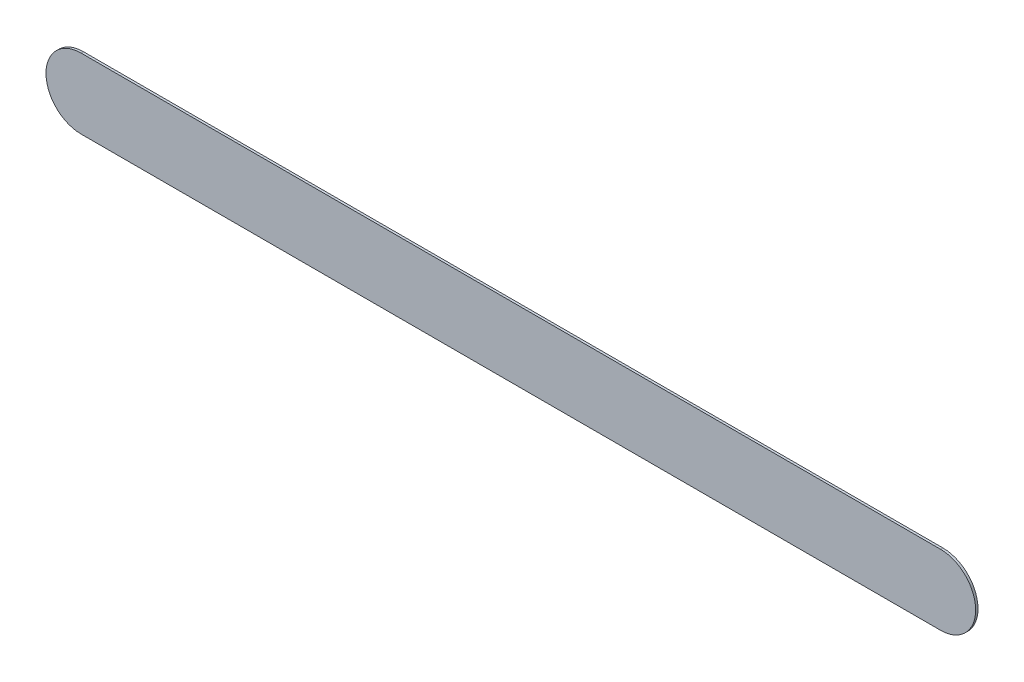
from build123d import *

# Parameters (mm, degrees)
BOSS_EXTRUDE2_DEPTH = 3


with BuildPart() as part:
    # Sketch1 → Boss-Extrude2 (new body)
    with BuildSketch(Plane.XY):
        with BuildLine():
            Line((-356.506, 44.9), (743.294, 44.9))
            ThreePointArc((743.294, 44.9), (788.194, 0), (743.294, -44.9))
            Line((743.294, -44.9), (-356.506, -44.9))
            ThreePointArc((-356.506, -44.9), (-401.406, 0), (-356.506, 44.9))
        make_face()
    extrude(amount=BOSS_EXTRUDE2_DEPTH)


solid = part.part
